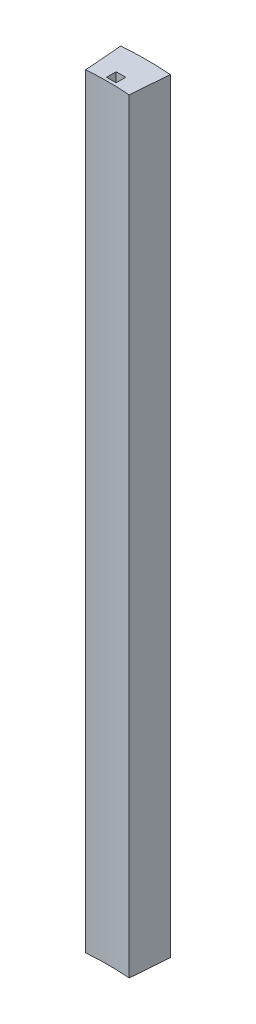
from build123d import *

# Parameters (mm, degrees)
SKETCH2_W           = 1.5875
SKETCH2_H           = 1.5875
BOSS_EXTRUDE1_DEPTH = 127


with BuildPart() as part:
    # Sketch2 → Boss-Extrude1 (new body)
    with BuildSketch(Plane(origin=(0, 0, 0), x_dir=(1, 0, 0), z_dir=(0, 1, 0))):
        with BuildLine():
            Line((-4.110275877, 52.226006821), (-3.61206062, 45.895581752))
            ThreePointArc((-3.61206062, 45.895581752), (0, 46.0375), (3.61206062, 45.895581752))
            Line((3.61206062, 45.895581752), (4.110275877, 52.226006821))
            ThreePointArc((4.110275877, 52.226006821), (0, 52.3875), (-4.110275877, 52.226006821))
        make_face()
        with Locations((0, 47.33925)):
            Rectangle(SKETCH2_W, SKETCH2_H, mode=Mode.SUBTRACT)
    extrude(amount=BOSS_EXTRUDE1_DEPTH)


solid = part.part
